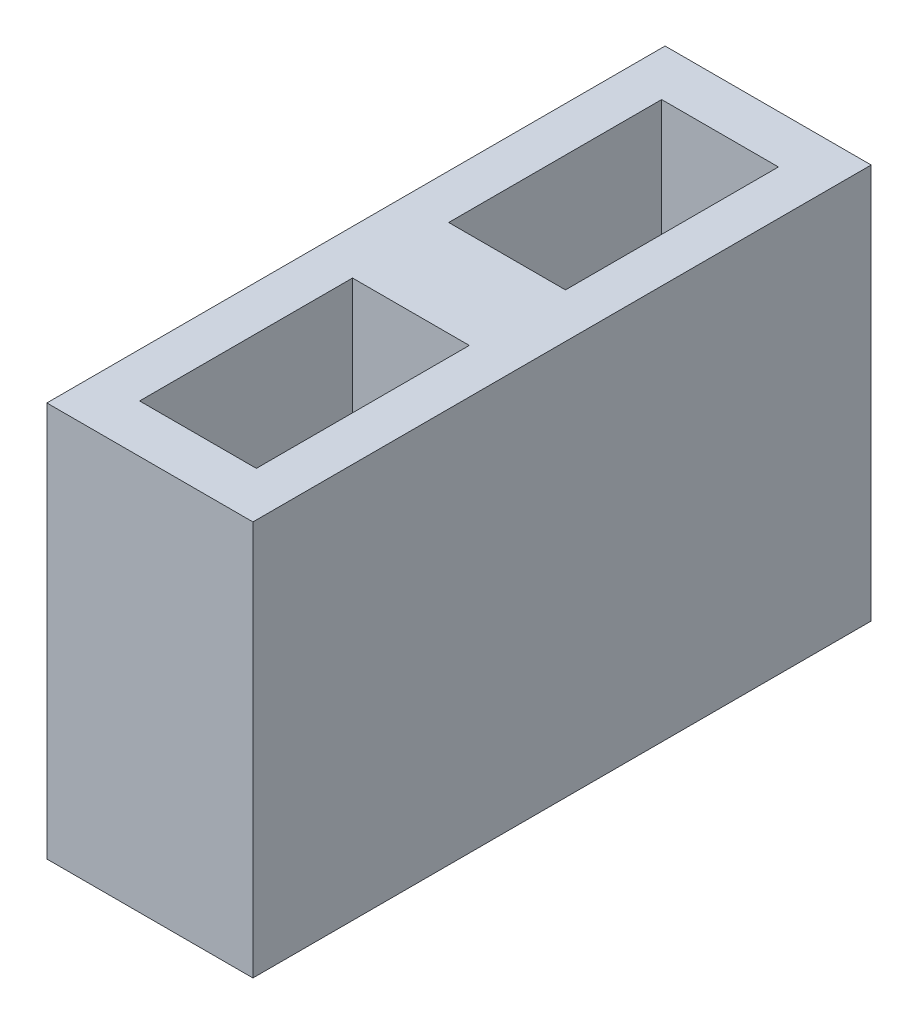
from build123d import *

# Parameters (mm, degrees)
BOSS_EXTRUDE1_DEPTH = 1.5
BOSS_EXTRUDE5_DEPTH = 10
SKETCH2_W           = 2.8
SKETCH2_H           = 2.8
BOSS_EXTRUDE2_DEPTH = 10
SKETCH4_W           = 6
SKETCH4_H           = 6
CUT_EXTRUDE1_DEPTH  = 12.5
BOSS_EXTRUDE6_DEPTH = 11.5
SKETCH8_W           = 6
SKETCH8_H           = 6
CUT_EXTRUDE3_DEPTH  = 12.5
BOSS_EXTRUDE8_DEPTH = 10


with BuildPart() as part:
    # Sketch1 → Boss-Extrude1 (new body)
    with BuildSketch(Plane(origin=(0, 0, 0), x_dir=(1, 0, 0), z_dir=(0, 1, 0))):
        Polygon((-3, 3), (-3, 9), (3, 9), (3, 3), (9, 3), (9, -3), (3, -3), (3, -9), (-3, -9), (-3, -3), (-9, -3), (-9, 3), align=None)
    extrude(amount=BOSS_EXTRUDE1_DEPTH)

    # Sketch3 → Boss-Extrude5 (add)
    with BuildSketch(Plane(origin=(0, 1.5, 0), x_dir=(1, 0, 0), z_dir=(0, 1, 0))):
        Polygon((-3, 3), (-9, 3), (-9, -3), (-3, -3), (-3, -9), (3, -9), (3, -3), (9, -3), (9, 3), (3, 3), (3, 9), (-3, 9), align=None)
        Polygon((-1.7, 1.7), (-7.6, 1.7), (-7.6, -1.7), (-1.7, -1.7), (-1.7, -7.6), (1.7, -7.6), (1.7, -1.7), (7.6, -1.7), (7.6, 1.7), (1.7, 1.7), (1.7, 7.6), (-1.7, 7.6), align=None, mode=Mode.SUBTRACT)
    extrude(amount=BOSS_EXTRUDE5_DEPTH)

    # Sketch2 → Boss-Extrude2 (add)
    with BuildSketch(Plane(origin=(0, 1.5, 0), x_dir=(1, 0, 0), z_dir=(0, 1, 0))):
        Rectangle(SKETCH2_W, SKETCH2_H)
    extrude(amount=BOSS_EXTRUDE2_DEPTH)

    # Sketch4 → Cut-Extrude1 (cut, through all)
    with BuildSketch(Plane(origin=(0, 11.5, 0), x_dir=(1, 0, 0), z_dir=(0, 1, 0))):
        with Locations((-6, 0)):
            Rectangle(SKETCH4_W, SKETCH4_H)
    extrude(amount=-CUT_EXTRUDE1_DEPTH, mode=Mode.SUBTRACT)

    # Sketch5 → Boss-Extrude6 (add)
    with BuildSketch(Plane(origin=(0, 11.5, 0), x_dir=(1, 0, 0), z_dir=(0, 1, 0))):
        Polygon((-3, 1.7), (-1.7, 1.7), (-1.7, 1.4), (-1.4, 1.4), (-1.4, -1.4), (-1.7, -1.4), (-1.7, -1.7), (-3, -1.7), align=None)
    extrude(amount=-BOSS_EXTRUDE6_DEPTH)

    # Sketch8 → Cut-Extrude3 (cut, through all)
    with BuildSketch(Plane(origin=(0, 11.5, 0), x_dir=(1, 0, 0), z_dir=(0, 1, 0))):
        with Locations((6, 0)):
            Rectangle(SKETCH8_W, SKETCH8_H)
    extrude(amount=-CUT_EXTRUDE3_DEPTH, mode=Mode.SUBTRACT)

    # Sketch9 → Boss-Extrude8 (add)
    with BuildSketch(Plane(origin=(0, 11.5, 0), x_dir=(1, 0, 0), z_dir=(0, 1, 0))):
        Polygon((1.4, -1.4), (1.4, 1.4), (1.7, 1.4), (1.7, 1.7), (3, 1.7), (3, -1.7), (1.7, -1.7), (1.7, -1.4), align=None)
    extrude(amount=-BOSS_EXTRUDE8_DEPTH)


solid = part.part
